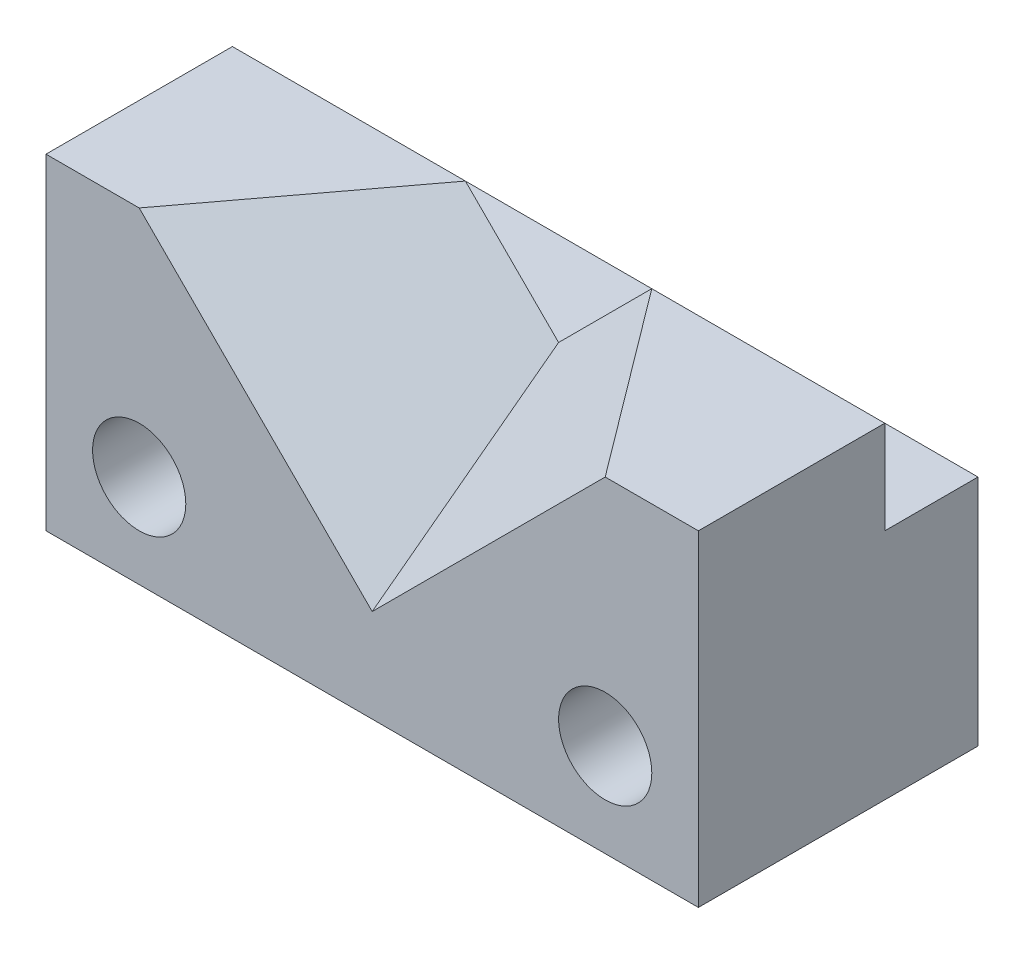
from build123d import *

# Parameters (mm, degrees)
SKETCH1_W           = 35
SKETCH1_H           = 30
BOSS_EXTRUDE1_DEPTH = 35
SKETCH2_W           = 35
SKETCH2_H           = 10
CUT_EXTRUDE1_DEPTH  = 10
CUT_EXTRUDE3_DEPTH  = 16.617376189
CUT_EXTRUDE4_DEPTH  = 21
CUT_EXTRUDE5_DEPTH  = 19
SKETCH13_R          = 5
CUT_EXTRUDE6_DEPTH  = 31
SKETCH14_R          = 5
CUT_EXTRUDE7_DEPTH  = 31


with BuildPart() as part:
    # Sketch1 → Boss-Extrude1 (new body)
    with BuildSketch(Plane(origin=(0, 0, 0), x_dir=(1, 0, 0), z_dir=(0, 1, 0))):
        with Locations((17.5, 15)):
            Rectangle(SKETCH1_W, SKETCH1_H)
    boss_extrude1 = extrude(amount=BOSS_EXTRUDE1_DEPTH)

    # Sketch2 → Cut-Extrude1 (cut)
    with BuildSketch(Plane(origin=(0, 35, 0), x_dir=(1, 0, 0), z_dir=(0, 1, 0))):
        with Locations((17.5, 25)):
            Rectangle(SKETCH2_W, SKETCH2_H)
    cut_extrude1 = extrude(amount=-CUT_EXTRUDE1_DEPTH, mode=Mode.SUBTRACT)

    # Sketch8 → Cut-Extrude3 (cut, through all)
    with BuildSketch(Plane(origin=(17.56097561, 17.56097561, 13.170731707), x_dir=(0.780868809, -0.499756038, -0.374817029), z_dir=(0.624695048, 0.624695048, 0.468521286))):
        Polygon((-9.682773237, 21), (22.33284795, 6), (22.33284795, 31), (9.526599475, 37), align=None)
    cut_extrude3 = extrude(amount=CUT_EXTRUDE3_DEPTH, mode=Mode.SUBTRACT)

    # Sketch10 → Cut-Extrude4 (cut, through all)
    with BuildSketch(Plane(origin=(0, 0, -20), x_dir=(-1, 0, 0), z_dir=(0, 0, -1))):
        Polygon((-35, 35), (-25, 35), (-35, 25), align=None)
    extrude(amount=-CUT_EXTRUDE4_DEPTH, mode=Mode.SUBTRACT)

    # Mirror5: Boss-Extrude1, Cut-Extrude1, Cut-Extrude3 across plane
    add(boss_extrude1.mirror(Plane(origin=(35, 35, 0), x_dir=(0, 0, 1), z_dir=(-1, 0, 0))))
    add(cut_extrude1.mirror(Plane(origin=(35, 35, 0), x_dir=(0, 0, 1), z_dir=(-1, 0, 0))), mode=Mode.SUBTRACT)
    add(cut_extrude3.mirror(Plane(origin=(35, 35, 0), x_dir=(0, 0, 1), z_dir=(-1, 0, 0))), mode=Mode.SUBTRACT)

    # Sketch12 → Cut-Extrude5 (cut)
    with BuildSketch(Plane(origin=(0, 0, -20), x_dir=(-1, 0, 0), z_dir=(0, 0, -1))):
        Polygon((-45, 35), (-35, 25), (-35, 35), align=None)
    extrude(amount=-CUT_EXTRUDE5_DEPTH, mode=Mode.SUBTRACT)

    # Sketch13 → Cut-Extrude6 (cut, through all)
    with BuildSketch(Plane.XY):
        with Locations((10, 10)):
            Circle(SKETCH13_R)
    extrude(amount=-CUT_EXTRUDE6_DEPTH, mode=Mode.SUBTRACT)

    # Sketch14 → Cut-Extrude7 (cut, through all)
    with BuildSketch(Plane.XY):
        with Locations((60, 10)):
            Circle(SKETCH14_R)
    extrude(amount=-CUT_EXTRUDE7_DEPTH, mode=Mode.SUBTRACT)


solid = part.part
